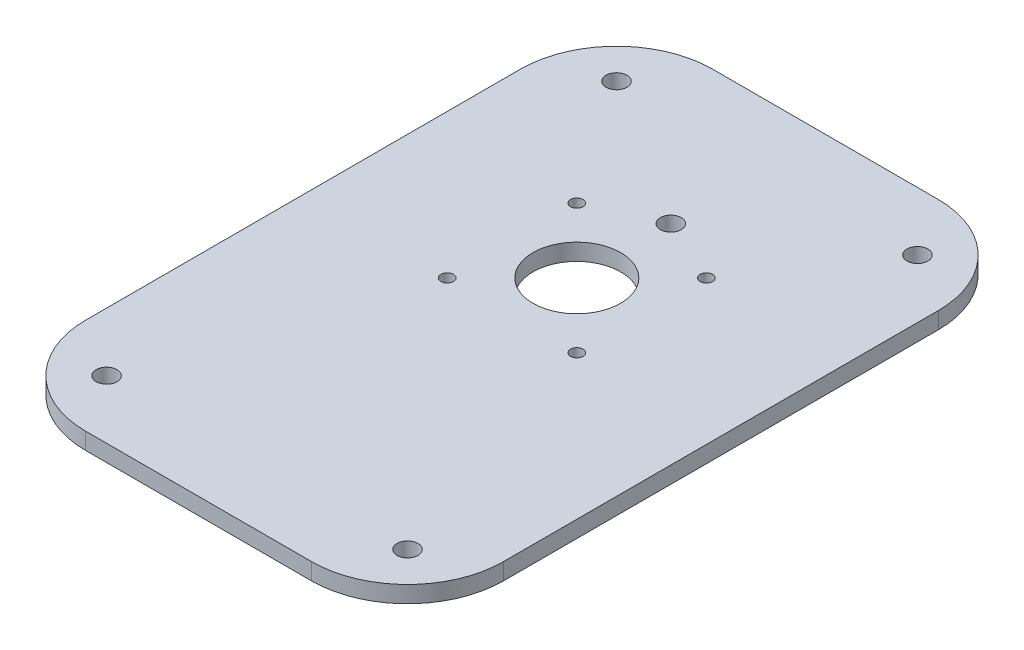
from build123d import *

# Parameters (mm, degrees)
SKETCH1_R           = 2.5
SKETCH1_R_2         = 10.5
SKETCH1_R_3         = 1.5
BOSS_EXTRUDE1_DEPTH = 4


with BuildPart() as part:
    # Sketch1 → Boss-Extrude1 (new body)
    with BuildSketch(Plane(origin=(0, 0, 0), x_dir=(1, 0, 0), z_dir=(0, 1, 0))):
        with BuildLine():
            Line((-27, -75), (27, -75))
            ThreePointArc((27, -75), (43.263455967, -68.263455967), (50, -52))
            Line((50, -52), (50, 52))
            ThreePointArc((50, 52), (43.263455967, 68.263455967), (27, 75))
            Line((27, 75), (-27, 75))
            ThreePointArc((-27, 75), (-43.263455967, 68.263455967), (-50, 52))
            Line((-50, 52), (-50, -52))
            ThreePointArc((-50, -52), (-43.263455967, -68.263455967), (-27, -75))
        make_face()
        with Locations((-36, 61)):
            Circle(SKETCH1_R, mode=Mode.SUBTRACT)
        with Locations((-36, -61)):
            Circle(SKETCH1_R, mode=Mode.SUBTRACT)
        with Locations((36, -61)):
            Circle(SKETCH1_R, mode=Mode.SUBTRACT)
        with Locations((36, 61)):
            Circle(SKETCH1_R, mode=Mode.SUBTRACT)
        with Locations((0, 38)):
            Circle(SKETCH1_R, mode=Mode.SUBTRACT)
        with Locations((0, 15.5)):
            Circle(SKETCH1_R_2, mode=Mode.SUBTRACT)
        with Locations((15.5, 31)):
            Circle(SKETCH1_R_3, mode=Mode.SUBTRACT)
        with Locations((-15.5, 31)):
            Circle(SKETCH1_R_3, mode=Mode.SUBTRACT)
        with Locations((-15.5, 0)):
            Circle(SKETCH1_R_3, mode=Mode.SUBTRACT)
        with Locations((15.5, 0)):
            Circle(SKETCH1_R_3, mode=Mode.SUBTRACT)
    extrude(amount=BOSS_EXTRUDE1_DEPTH)


solid = part.part
